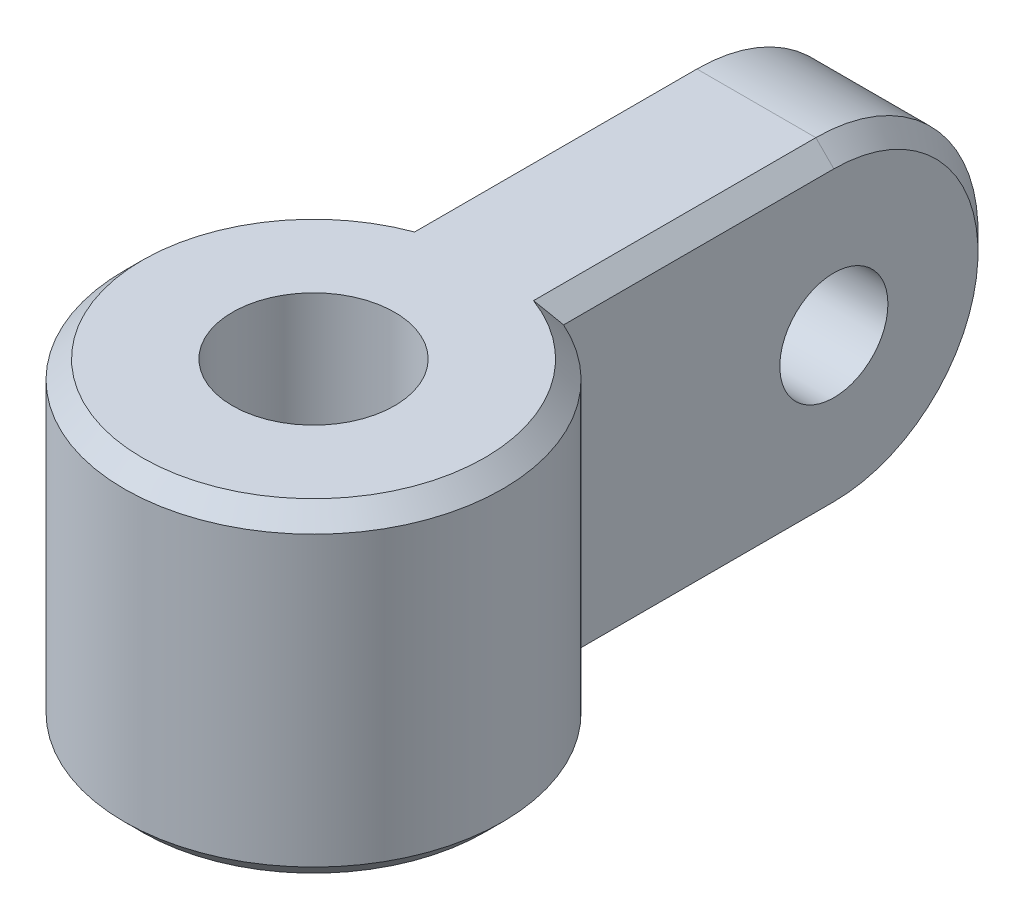
from build123d import *

# Parameters (mm, degrees)
SKETCH1_R           = 2.25
SKETCH1_W           = 4.3
SKETCH1_H           = 3
BOSS_EXTRUDE1_DEPTH = 9
SKETCH3_R           = 1.5
BOSS_EXTRUDE2_DEPTH = 4.3
CHAMFER1_SIZE       = 0.5


with BuildPart() as part:
    # Sketch1 → Boss-Extrude1 (new body)
    with BuildSketch(Plane(origin=(0, 0, 0), x_dir=(1, 0, 0), z_dir=(0, 1, 0))):
        with BuildLine():
            Line((-2.15, 4.789572006), (2.15, 4.789572006))
            ThreePointArc((2.15, 4.789572006), (0, -5.25), (-2.15, 4.789572006))
        make_face()
        Circle(SKETCH1_R, mode=Mode.SUBTRACT)
        with Locations((0, 6.289572006)):
            Rectangle(SKETCH1_W, SKETCH1_H)
    extrude(amount=BOSS_EXTRUDE1_DEPTH)

    # Sketch3 → Boss-Extrude2 (add)
    with BuildSketch(Plane(origin=(2.15, 0, 0), x_dir=(0, 0, -1), z_dir=(1, 0, 0))):
        with BuildLine():
            ThreePointArc((12.289572006, 9), (16.789572006, 4.5), (12.289572006, 0))
            Line((12.289572006, 0), (7.789572006, 0))
            Line((7.789572006, 0), (7.789572006, 9))
            Line((7.789572006, 9), (12.289572006, 9))
        make_face()
        with Locations((12.289572006, 4.5)):
            Circle(SKETCH3_R, mode=Mode.SUBTRACT)
    extrude(amount=-BOSS_EXTRUDE2_DEPTH)

    # Chamfer1
    chamfer1_edges = [part.edges().sort_by_distance(p)[0] for p in [
        (0, 9, 5.25),
        (2.15, 9, -8.539572006),
        (2.15, 4.5, -16.789572006),
        (-2.15, 4.5, -16.789572006),
        (-2.15, 9, -8.539572006),
        (-2.15, 0, -8.539572006),
        (2.15, 0, -8.539572006),
        (0, 0, 5.25),
    ]]
    chamfer(chamfer1_edges, length=CHAMFER1_SIZE)


solid = part.part
